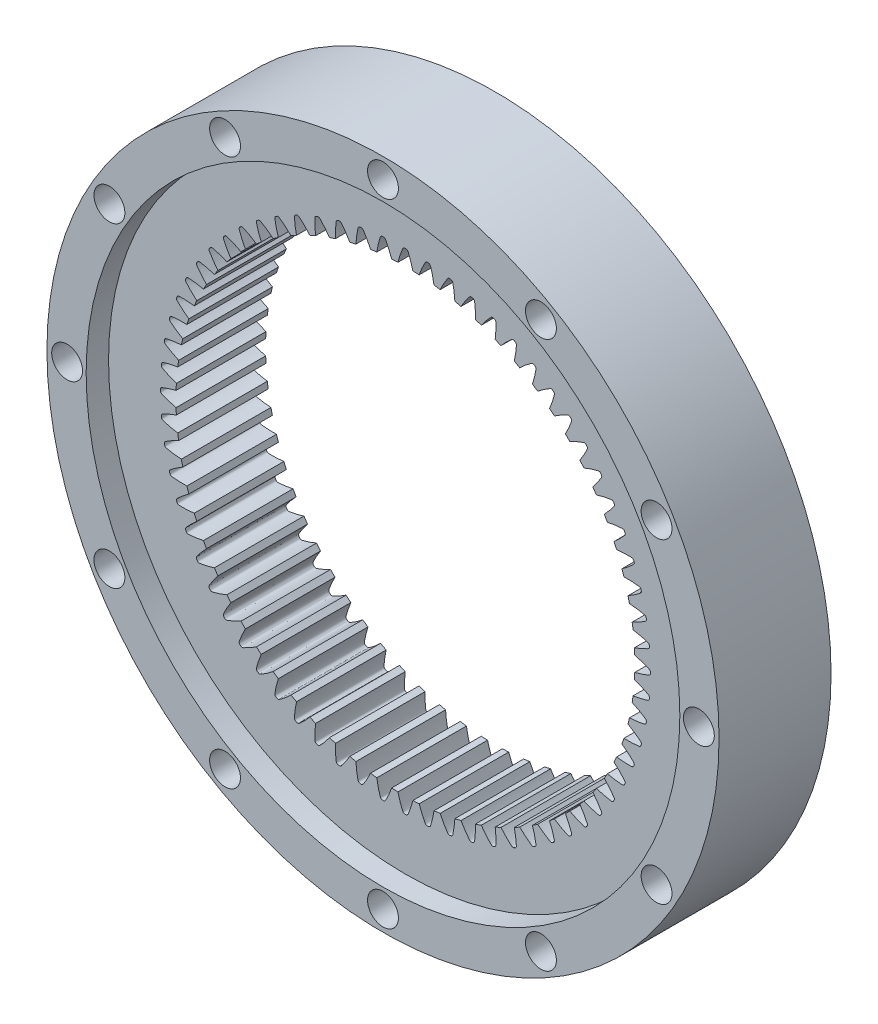
from build123d import *

# Parameters (mm, degrees)
SKETCHREVOLVERING_GEAR_FOLLOWER01_W       = 12.7
SKETCHREVOLVERING_GEAR_FOLLOWER01_H       = 12.088250957
TOOTHEXTRUDECUTRING_GEAR_FOLLOWER01_DEPTH = 6.35
PATTERNRING_GEAR_FOLLOWER01_COUNT         = 68
SKETCH1_R                                 = 33.655
CUT_EXTRUDE1_DEPTH                        = 2.54
SKETCH2_R                                 = 1.75
CUT_EXTRUDE2_DEPTH                        = 56.358016744


with BuildPart() as part:
    # SketchRevolveRing_Gear_Follower01 → Ring_Gear_Follower01 (revolve)
    with BuildSketch(Plane(origin=(0, 0, 0), x_dir=(0, 0, -1), z_dir=(1, 0, 0))):
        with Locations((0, 32.055874522)):
            Rectangle(SKETCHREVOLVERING_GEAR_FOLLOWER01_W, SKETCHREVOLVERING_GEAR_FOLLOWER01_H)
    revolve(axis=Axis((0, 0, 0), (0, 0, -1)))

    # SketchToothRing_Gear_Follower01 → ToothExtrudeCutRing_Gear_Follower01 (cut, symmetric)
    with BuildSketch(Plane.XY):
        with BuildLine():
            ThreePointArc((25.841581056, -0.877315347), (25.856469088, 0), (25.841581056, 0.877315347))
            add(Edge.make_bspline(
                [(25.841581056, 0.877315347), (25.93394438, 0.859095786), (26.077789137, 0.827156459), (26.275992391, 0.776518272), (26.441414177, 0.730363864), (26.617450855, 0.677021943), (26.803928954, 0.616121181), (27.000314944, 0.546698544), (27.207460689, 0.470242879), (27.431243142, 0.373706324), (27.608384889, 0.318508246), (27.703151856, 0.250803099), (27.72735641, 0.226635248), (27.747972016, 0.199379761), (27.76438083, 0.169398856), (27.780356819, 0.127186732), (27.785971447, 0.081461523), (27.785096671, 0.035556984), (27.785367745, 0), (27.785096671, -0.035556984), (27.785971447, -0.081461523), (27.780356819, -0.127186732), (27.76438083, -0.169398856), (27.747972016, -0.199379761), (27.72735641, -0.226635248), (27.703151856, -0.250803099), (27.608384889, -0.318508246), (27.431243142, -0.373706324), (27.207460689, -0.470242879), (27.000314944, -0.546698544), (26.803928954, -0.616121181), (26.617450855, -0.677021943), (26.441414177, -0.730363864), (26.275992391, -0.776518272), (26.077789137, -0.827156459), (25.93394438, -0.859095786), (25.841581056, -0.877315347)],
                knots=[0, 0, 0, 0, 0.06293672, 0.098485295, 0.136754012, 0.177742872, 0.221451875, 0.267881021, 0.31703031, 0.368899741, 0.431324234, 0.438915325, 0.446506415, 0.454097506, 0.461688597, 0.469279688, 0.484155493, 0.492077753, 0.5, 0.507922247, 0.515844507, 0.530720312, 0.538311403, 0.545902494, 0.553493585, 0.561084675, 0.568675766, 0.631100259, 0.68296969, 0.732118979, 0.778548125, 0.822257128, 0.863245988, 0.901514705, 0.93706328, 1, 1, 1, 1], degree=3))
        make_face()
    toothextrudecutring_gear_follower01 = extrude(amount=TOOTHEXTRUDECUTRING_GEAR_FOLLOWER01_DEPTH, both=True, mode=Mode.SUBTRACT)

    # PatternRing_Gear_Follower01: ToothExtrudeCutRing_Gear_Follower01 ×68 about axis
    patternring_gear_follower01_axis = Axis((0, 0, 55), (0, 0, -1))
    for i in range(1, PATTERNRING_GEAR_FOLLOWER01_COUNT):
        add(toothextrudecutring_gear_follower01.rotate(patternring_gear_follower01_axis, i * 360 / PATTERNRING_GEAR_FOLLOWER01_COUNT), mode=Mode.SUBTRACT)

    # Sketch1 → Cut-Extrude1 (cut)
    with BuildSketch(Plane.XY.offset(6.35)):
        Circle(SKETCH1_R)
    extrude(amount=-CUT_EXTRUDE1_DEPTH, mode=Mode.SUBTRACT)

    # Sketch2 → Cut-Extrude2 (cut, through all)
    with BuildSketch(Plane.XY.offset(6.35)):
        with Locations((0, 35.814)):
            Circle(SKETCH2_R)
        with Locations((17.907, 31.015833811)):
            Circle(SKETCH2_R)
        with Locations((31.015833811, 17.907)):
            Circle(SKETCH2_R)
        with Locations((35.814, 0)):
            Circle(SKETCH2_R)
        with Locations((31.015833811, -17.907)):
            Circle(SKETCH2_R)
        with Locations((17.907, -31.015833811)):
            Circle(SKETCH2_R)
        with Locations((0, -35.814)):
            Circle(SKETCH2_R)
        with Locations((-17.907, -31.015833811)):
            Circle(SKETCH2_R)
        with Locations((-31.015833811, -17.907)):
            Circle(SKETCH2_R)
        with Locations((-35.814, 0)):
            Circle(SKETCH2_R)
        with Locations((-31.015833811, 17.907)):
            Circle(SKETCH2_R)
        with Locations((-17.907, 31.015833811)):
            Circle(SKETCH2_R)
    extrude(amount=-CUT_EXTRUDE2_DEPTH, mode=Mode.SUBTRACT)


solid = part.part
